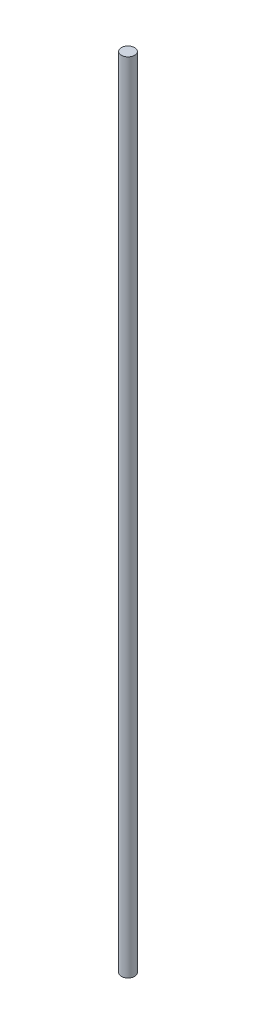
from build123d import *

# Parameters (mm, degrees)
SKETCH1_R           = 10
BOSS_EXTRUDE1_DEPTH = 1200


with BuildPart() as part:
    # Sketch1 → Boss-Extrude1 (new body)
    with BuildSketch(Plane(origin=(0, 0, 0), x_dir=(1, 0, 0), z_dir=(0, 1, 0))):
        Circle(SKETCH1_R)
    extrude(amount=BOSS_EXTRUDE1_DEPTH)


solid = part.part
